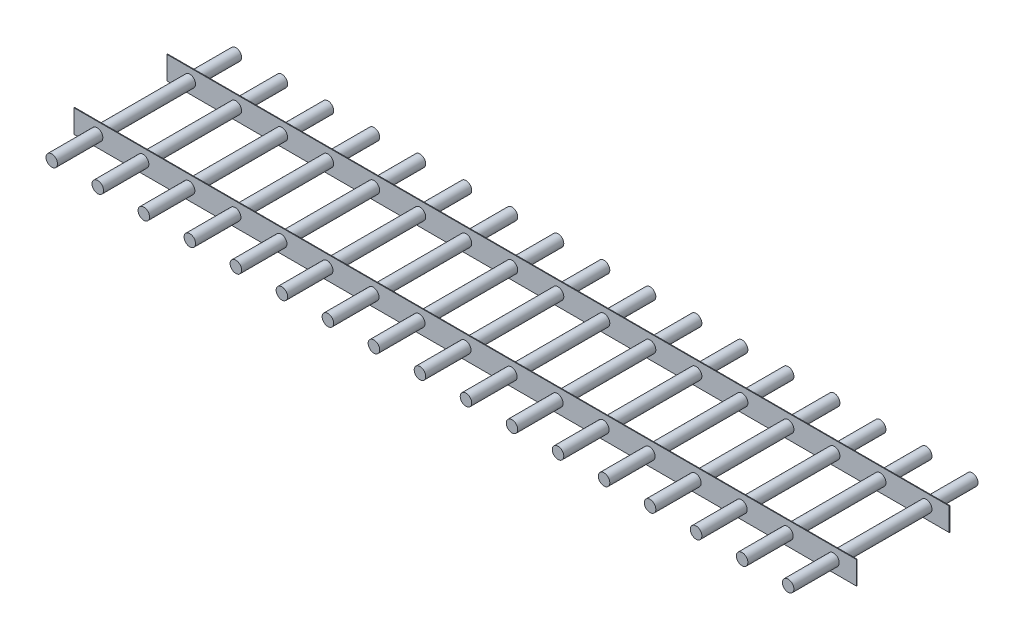
from build123d import *

# Parameters (mm, degrees)
SKETCH1_R              = 3.175
BOSS_EXTRUDE1_DEPTH    = 50.8
BOSS_EXTRUDE1_2_DEPTH  = 50.8
BOSS_EXTRUDE1_3_DEPTH  = 50.8
BOSS_EXTRUDE1_4_DEPTH  = 50.8
BOSS_EXTRUDE1_5_DEPTH  = 50.8
BOSS_EXTRUDE1_6_DEPTH  = 50.8
BOSS_EXTRUDE1_7_DEPTH  = 50.8
BOSS_EXTRUDE1_8_DEPTH  = 50.8
BOSS_EXTRUDE1_9_DEPTH  = 50.8
BOSS_EXTRUDE1_10_DEPTH = 50.8
BOSS_EXTRUDE1_11_DEPTH = 50.8
BOSS_EXTRUDE1_12_DEPTH = 50.8
BOSS_EXTRUDE1_13_DEPTH = 50.8
BOSS_EXTRUDE1_14_DEPTH = 50.8
BOSS_EXTRUDE1_15_DEPTH = 50.8
BOSS_EXTRUDE1_16_DEPTH = 50.8
BOSS_EXTRUDE1_17_DEPTH = 50.8
SKETCH2_W              = 431.8
SKETCH2_H              = 12.7
BOSS_EXTRUDE2_DEPTH    = 0.381


with BuildPart() as part:
    # Sketch1 → Boss-Extrude1 (new body, symmetric)
    with BuildSketch(Plane.XY):
        Circle(SKETCH1_R)
    extrude(amount=BOSS_EXTRUDE1_DEPTH, both=True)



with BuildPart() as body_2:
    # Sketch1 → Boss-Extrude1 2 (new body, symmetric)
    with BuildSketch(Plane.XY):
        with Locations((25.4, 0)):
            Circle(SKETCH1_R)
    extrude(amount=BOSS_EXTRUDE1_2_DEPTH, both=True)


with BuildPart() as body_3:
    # Sketch1 → Boss-Extrude1 3 (new body, symmetric)
    with BuildSketch(Plane.XY):
        with Locations((50.8, 0)):
            Circle(SKETCH1_R)
    extrude(amount=BOSS_EXTRUDE1_3_DEPTH, both=True)


with BuildPart() as body_4:
    # Sketch1 → Boss-Extrude1 4 (new body, symmetric)
    with BuildSketch(Plane.XY):
        with Locations((76.2, 0)):
            Circle(SKETCH1_R)
    extrude(amount=BOSS_EXTRUDE1_4_DEPTH, both=True)


with BuildPart() as body_5:
    # Sketch1 → Boss-Extrude1 5 (new body, symmetric)
    with BuildSketch(Plane.XY):
        with Locations((101.6, 0)):
            Circle(SKETCH1_R)
    extrude(amount=BOSS_EXTRUDE1_5_DEPTH, both=True)


with BuildPart() as body_6:
    # Sketch1 → Boss-Extrude1 6 (new body, symmetric)
    with BuildSketch(Plane.XY):
        with Locations((127, 0)):
            Circle(SKETCH1_R)
    extrude(amount=BOSS_EXTRUDE1_6_DEPTH, both=True)


with BuildPart() as body_7:
    # Sketch1 → Boss-Extrude1 7 (new body, symmetric)
    with BuildSketch(Plane.XY):
        with Locations((152.4, 0)):
            Circle(SKETCH1_R)
    extrude(amount=BOSS_EXTRUDE1_7_DEPTH, both=True)


with BuildPart() as body_8:
    # Sketch1 → Boss-Extrude1 8 (new body, symmetric)
    with BuildSketch(Plane.XY):
        with Locations((177.8, 0)):
            Circle(SKETCH1_R)
    extrude(amount=BOSS_EXTRUDE1_8_DEPTH, both=True)


with BuildPart() as body_9:
    # Sketch1 → Boss-Extrude1 9 (new body, symmetric)
    with BuildSketch(Plane.XY):
        with Locations((203.2, 0)):
            Circle(SKETCH1_R)
    extrude(amount=BOSS_EXTRUDE1_9_DEPTH, both=True)


with BuildPart() as body_10:
    # Sketch1 → Boss-Extrude1 10 (new body, symmetric)
    with BuildSketch(Plane.XY):
        with Locations((228.6, 0)):
            Circle(SKETCH1_R)
    extrude(amount=BOSS_EXTRUDE1_10_DEPTH, both=True)


with BuildPart() as body_11:
    # Sketch1 → Boss-Extrude1 11 (new body, symmetric)
    with BuildSketch(Plane.XY):
        with Locations((254, 0)):
            Circle(SKETCH1_R)
    extrude(amount=BOSS_EXTRUDE1_11_DEPTH, both=True)


with BuildPart() as body_12:
    # Sketch1 → Boss-Extrude1 12 (new body, symmetric)
    with BuildSketch(Plane.XY):
        with Locations((279.4, 0)):
            Circle(SKETCH1_R)
    extrude(amount=BOSS_EXTRUDE1_12_DEPTH, both=True)


with BuildPart() as body_13:
    # Sketch1 → Boss-Extrude1 13 (new body, symmetric)
    with BuildSketch(Plane.XY):
        with Locations((304.8, 0)):
            Circle(SKETCH1_R)
    extrude(amount=BOSS_EXTRUDE1_13_DEPTH, both=True)


with BuildPart() as body_14:
    # Sketch1 → Boss-Extrude1 14 (new body, symmetric)
    with BuildSketch(Plane.XY):
        with Locations((330.2, 0)):
            Circle(SKETCH1_R)
    extrude(amount=BOSS_EXTRUDE1_14_DEPTH, both=True)


with BuildPart() as body_15:
    # Sketch1 → Boss-Extrude1 15 (new body, symmetric)
    with BuildSketch(Plane.XY):
        with Locations((355.6, 0)):
            Circle(SKETCH1_R)
    extrude(amount=BOSS_EXTRUDE1_15_DEPTH, both=True)


with BuildPart() as body_16:
    # Sketch1 → Boss-Extrude1 16 (new body, symmetric)
    with BuildSketch(Plane.XY):
        with Locations((381, 0)):
            Circle(SKETCH1_R)
    extrude(amount=BOSS_EXTRUDE1_16_DEPTH, both=True)


with BuildPart() as body_17:
    # Sketch1 → Boss-Extrude1 17 (new body, symmetric)
    with BuildSketch(Plane.XY):
        with Locations((406.4, 0)):
            Circle(SKETCH1_R)
    extrude(amount=BOSS_EXTRUDE1_17_DEPTH, both=True)


with BuildPart() as part_1:
    add(part.part)

    add(body_2.part)  # Boss-Extrude2 merges body 2

    add(body_3.part)  # Boss-Extrude2 merges body 3

    add(body_4.part)  # Boss-Extrude2 merges body 4

    add(body_5.part)  # Boss-Extrude2 merges body 5

    add(body_6.part)  # Boss-Extrude2 merges body 6

    add(body_7.part)  # Boss-Extrude2 merges body 7

    add(body_8.part)  # Boss-Extrude2 merges body 8

    add(body_9.part)  # Boss-Extrude2 merges body 9

    add(body_10.part)  # Boss-Extrude2 merges body 10

    add(body_11.part)  # Boss-Extrude2 merges body 11

    add(body_12.part)  # Boss-Extrude2 merges body 12

    add(body_13.part)  # Boss-Extrude2 merges body 13

    add(body_14.part)  # Boss-Extrude2 merges body 14

    add(body_15.part)  # Boss-Extrude2 merges body 15

    add(body_16.part)  # Boss-Extrude2 merges body 16

    add(body_17.part)  # Boss-Extrude2 merges body 17
    # Sketch2 → Boss-Extrude2 (add)
    with BuildSketch(Plane.XY.offset(25.4)):
        with Locations((203.2, 0)):
            Rectangle(SKETCH2_W, SKETCH2_H)
    boss_extrude2 = extrude(amount=BOSS_EXTRUDE2_DEPTH)

    # Mirror1: Boss-Extrude2 across plane
    add(boss_extrude2.mirror(Plane.XY))


solid = part_1.part
